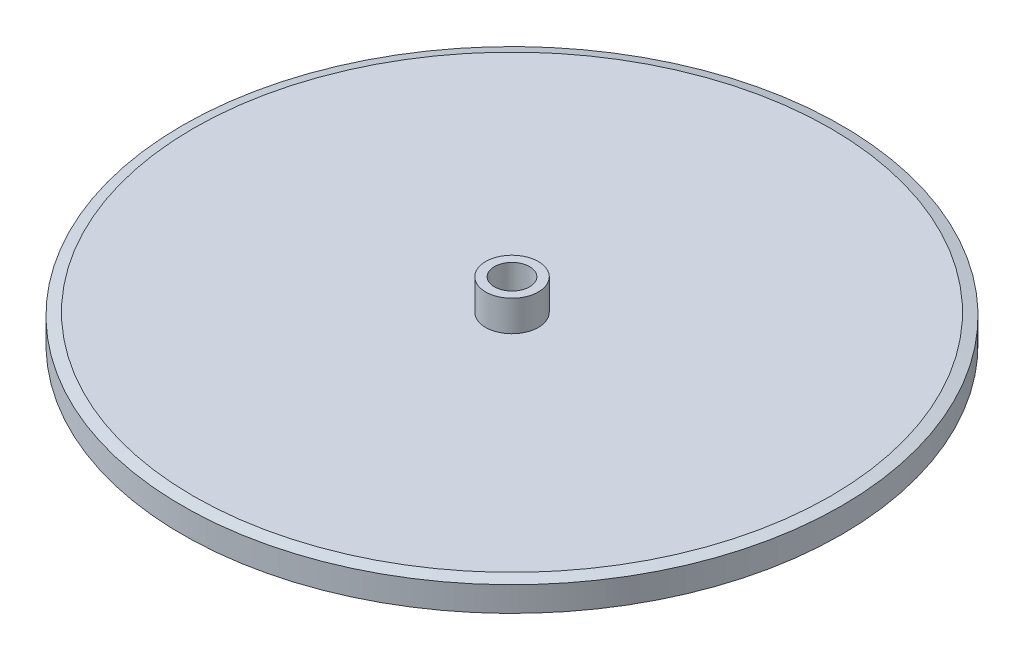
from build123d import *

# Parameters (mm, degrees)
CHAMFER_1_SIZE           = 1.25
CHAMFER_1_SIZE2          = 0.334936491
SKETCH_2_R               = 2
CUT_EXTRUDE_3_DEPTH      = 1
CUT_EXTRUDE_3_DEPTH_BACK = 8
CHAMFER_2_SIZE           = 1.25
CHAMFER_2_SIZE2          = 0.334936491


with BuildPart() as part:
    # Эскиз1 → Повернуть2 (revolve)
    with BuildSketch(Plane.XY):
        Polygon((0, 0), (37.5, 0), (37.5, 3.5), (3, 3.5), (3, 7), (0, 7), align=None)
    revolve(axis=Axis((0, 7, 0), (0, -1, 0)))

    # Фаска1
    chamfer_1_edges = [part.edges().sort_by_distance(p)[0] for p in [
        (-37.5, 3.5, 0),
    ]]
    chamfer_1_side = [part.faces().sort_by_distance(p)[0] for p in [
        (-36.439339828, 3.5, 0),
    ]]
    chamfer(chamfer_1_edges, length=CHAMFER_1_SIZE, length2=CHAMFER_1_SIZE2, reference=chamfer_1_side[0])

    # Эскиз2 → Вырез-Вытянуть3 (cut, two sides)
    with BuildSketch(Plane(origin=(0, 0, 0), x_dir=(-1, 0, 0), z_dir=(0, -1, 0))) as cut_extrude_3_sk:
        Circle(SKETCH_2_R)
    extrude(amount=CUT_EXTRUDE_3_DEPTH, mode=Mode.SUBTRACT)
    extrude(cut_extrude_3_sk.sketch, amount=-CUT_EXTRUDE_3_DEPTH_BACK, mode=Mode.SUBTRACT)

    # Фаска2
    chamfer_2_edges = [part.edges().sort_by_distance(p)[0] for p in [
        (-37.5, 0, 0),
    ]]
    chamfer_2_side = [part.faces().sort_by_distance(p)[0] for p in [
        (-36.439339828, 0, 0),
    ]]
    chamfer(chamfer_2_edges, length=CHAMFER_2_SIZE, length2=CHAMFER_2_SIZE2, reference=chamfer_2_side[0])


solid = part.part
